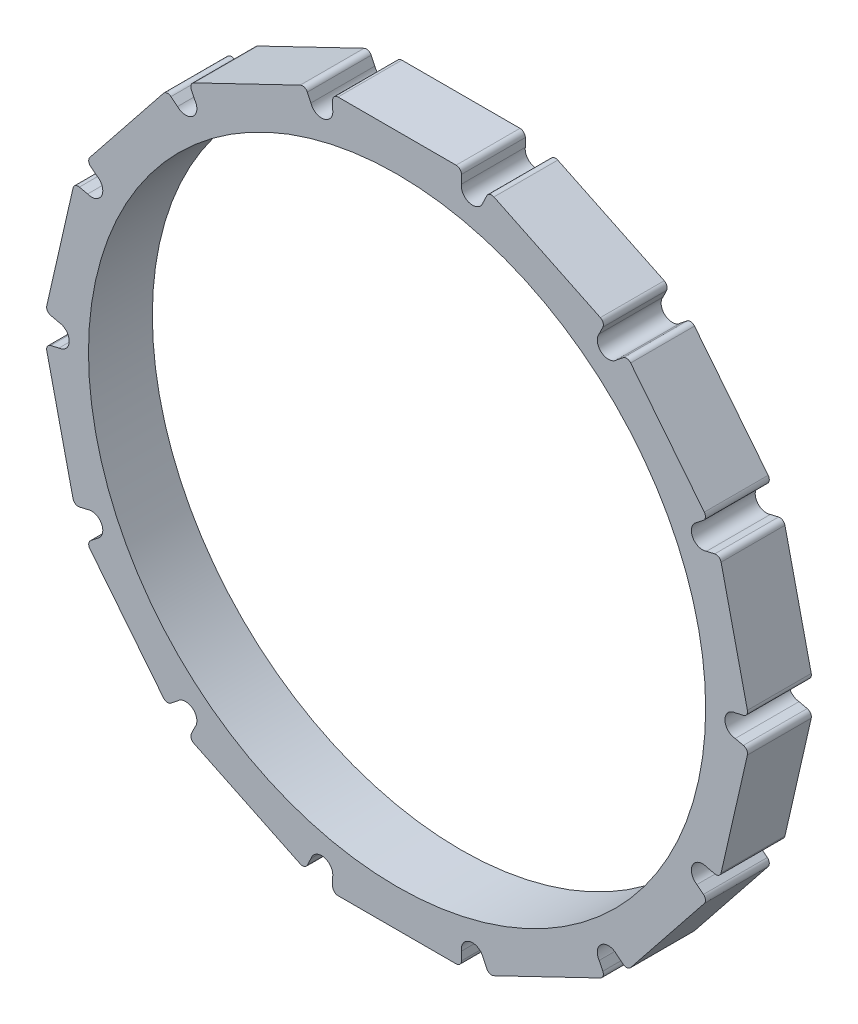
from build123d import *
from build123d.topology import SkipClean

# Parameters (mm, degrees)
SKETCH_1_R               = 34.5
EXTRUDE_1_DEPTH          = 4
SKETCH_2_R               = 31.5
EXTRUDE_2_DEPTH          = 3
SKETCH_3_W               = 12.1
SKETCH_3_H               = 2
EXTRUDE_3_DEPTH          = 3
PATTERN_CIRCULAR_1_COUNT = 14
SKETCH_5_R               = 1.05
CUT_EXTRUDE_1_DEPTH      = 3
PATTERN_CIRCULAR_2_COUNT = 14
SKETCH_6_R               = 4.5
CUT_EXTRUDE_2_DEPTH      = 50.289958409
SKETCH_7_R               = 29
SKETCH_7_R_2             = 10.5
CUT_EXTRUDE_3_DEPTH      = 50.289958409
CUT_EXTRUDE_3_DEPTH_BACK = 50.289958409
EXTRUDE_4_DEPTH          = 7
PATTERN_CIRCULAR_3_COUNT = 6
MIRROR_1_COPY_1_DEPTH    = 7
MIRROR_1_COPY_2_DEPTH    = 7
MIRROR_1_COPY_3_DEPTH    = 7
MIRROR_1_COPY_4_DEPTH    = 7
MIRROR_1_COPY_5_DEPTH    = 7
FILLET_1_R               = 0.5
FILLET_2_R               = 0.5
SKETCH_9_R               = 34.5
CUT_EXTRUDE_4_DEPTH      = 4
SKETCH_10_R              = 29
CUT_EXTRUDE_5_DEPTH      = 47.366061942
SKETCH_11_R              = 29
EXTRUDE_5_DEPTH          = 3


with BuildPart() as part:
    # ｽｹｯﾁ1 → ﾎﾞｽ - 押し出し1 (new body)
    with BuildSketch(Plane.XY):
        Circle(SKETCH_1_R)
    extrude(amount=EXTRUDE_1_DEPTH)

    # ｽｹｯﾁ2 → ﾎﾞｽ - 押し出し2 (add)
    with BuildSketch(Plane.XY.offset(4)):
        Circle(SKETCH_2_R)
    extrude(amount=EXTRUDE_2_DEPTH)

    # ｽｹｯﾁ3 → ﾎﾞｽ - 押し出し3 (add)
    with BuildSketch(Plane.XY.offset(4)):
        with Locations((0, 31.5)):
            Rectangle(SKETCH_3_W, SKETCH_3_H)
    extrude_3 = extrude(amount=EXTRUDE_3_DEPTH)

    # 円形ﾊﾟﾀｰﾝ1: ﾎﾞｽ - 押し出し3 ×14 about axis
    pattern_circular_1_axis = Axis((0, 0, 0), (0, 0, 1))
    for i in range(1, PATTERN_CIRCULAR_1_COUNT):
        add(extrude_3.rotate(pattern_circular_1_axis, i * 360 / PATTERN_CIRCULAR_1_COUNT))

    # ｽｹｯﾁ5 → ｶｯﾄ - 押し出し1 (cut)
    with BuildSketch(Plane.XY.offset(7)):
        with Locations((-7.089547386, 31.061336605)):
            Circle(SKETCH_5_R)
    cut_extrude_1 = extrude(amount=-CUT_EXTRUDE_1_DEPTH, mode=Mode.SUBTRACT)

    # 円形ﾊﾟﾀｰﾝ2: ｶｯﾄ - 押し出し1 ×14 about axis
    pattern_circular_2_axis = Axis((0, 0, 0), (0, 0, 1))
    for i in range(1, PATTERN_CIRCULAR_2_COUNT):
        add(cut_extrude_1.rotate(pattern_circular_2_axis, i * 360 / PATTERN_CIRCULAR_2_COUNT), mode=Mode.SUBTRACT)

    # ｽｹｯﾁ6 → ｶｯﾄ - 押し出し2 (cut, through all)
    with BuildSketch(Plane.XY.offset(7)):
        Circle(SKETCH_6_R)
    extrude(amount=-CUT_EXTRUDE_2_DEPTH, mode=Mode.SUBTRACT)

    # ｽｹｯﾁ7 → ｶｯﾄ - 押し出し3 (cut, two sides)
    with BuildSketch(Plane.XY.offset(7)) as cut_extrude_3_sk:
        Circle(SKETCH_7_R)
        Circle(SKETCH_7_R_2, mode=Mode.SUBTRACT)
    extrude(amount=CUT_EXTRUDE_3_DEPTH, mode=Mode.SUBTRACT)
    extrude(cut_extrude_3_sk.sketch, amount=-CUT_EXTRUDE_3_DEPTH_BACK, mode=Mode.SUBTRACT)


with BuildPart() as cut_extrude_3_piece_1:
    # of the separate pieces the step leaves, piece 1, a body of its own (cut_extrude_3_pieces)
    add(part.part.solids().sort_by_distance((34.5, 0, 0))[0])



with BuildPart() as cut_extrude_3_piece_2:
    # of the separate pieces the step leaves, piece 2, a body of its own (cut_extrude_3_pieces)
    add(part.part.solids().sort_by_distance((10.5, 0, 0))[0])


with BuildPart() as cut_extrude_3_piece_1_1:
    add(cut_extrude_3_piece_1.part)

    add(cut_extrude_3_piece_2.part)  # ﾎﾞｽ - 押し出し4 merges ｶｯﾄ - 押し出し3 piece 2
    # ｽｹｯﾁ8 → ﾎﾞｽ - 押し出し4 (add)
    with BuildSketch(Plane.XY.offset(7)):
        with BuildLine():
            Line((-10.232853034, 2.353448276), (-4.173869521, 28.698062883))
            ThreePointArc((-4.173869521, 28.698062883), (-2.092388157, 28.924417225), (0, 29))
            Line((0, 29), (-4.486334578, 9.493303011))
            ThreePointArc((-4.486334578, 9.493303011), (-8.179731193, 6.583463952), (-10.232853034, 2.353448276))
        make_face()
    extrude_4 = extrude(amount=-EXTRUDE_4_DEPTH)

    # 円形ﾊﾟﾀｰﾝ3: ﾎﾞｽ - 押し出し4 ×6 about axis
    pattern_circular_3_axis = Axis((0, 0, 0), (0, 0, 1))
    for i in range(1, PATTERN_CIRCULAR_3_COUNT):
        add(extrude_4.rotate(pattern_circular_3_axis, i * 360 / PATTERN_CIRCULAR_3_COUNT))

    # ﾐﾗｰ1: ﾎﾞｽ - 押し出し4 across plane
    add(extrude_4.mirror(Plane(origin=(0, 0, 0), x_dir=(0, 0, 1), z_dir=(1, 0, 0))))

    # ﾐﾗｰ1 copy 1 sketch → ﾐﾗｰ1 copy 1 (add)
    with BuildSketch(Plane(origin=(0, 0, 7), x_dir=(-0.5000000000000001, 0.8660254037844386, 0), z_dir=(0, 0, 1))):
        with BuildLine():
            Line((-10.232853034, -2.353448276), (-4.173869521, -28.698062883))
            ThreePointArc((-4.173869521, -28.698062883), (-2.092388157, -28.924417225), (0, -29))
            Line((0, -29), (-4.486334578, -9.493303011))
            ThreePointArc((-4.486334578, -9.493303011), (-8.179731193, -6.583463952), (-10.232853034, -2.353448276))
        make_face()
    extrude(amount=-MIRROR_1_COPY_1_DEPTH)

    # ﾐﾗｰ1 copy 2 sketch → ﾐﾗｰ1 copy 2 (add)
    with BuildSketch(Plane(origin=(0, 0, 7), x_dir=(0.4999999999999998, 0.8660254037844387, 0), z_dir=(0, 0, 1))):
        with BuildLine():
            Line((-10.232853034, -2.353448276), (-4.173869521, -28.698062883))
            ThreePointArc((-4.173869521, -28.698062883), (-2.092388157, -28.924417225), (0, -29))
            Line((0, -29), (-4.486334578, -9.493303011))
            ThreePointArc((-4.486334578, -9.493303011), (-8.179731193, -6.583463952), (-10.232853034, -2.353448276))
        make_face()
    extrude(amount=-MIRROR_1_COPY_2_DEPTH)

    # ﾐﾗｰ1 copy 3 sketch → ﾐﾗｰ1 copy 3 (add)
    with BuildSketch(Plane.XY.offset(7)):
        with BuildLine():
            Line((-10.232853034, -2.353448276), (-4.173869521, -28.698062883))
            ThreePointArc((-4.173869521, -28.698062883), (-2.092388157, -28.924417225), (0, -29))
            Line((0, -29), (-4.486334578, -9.493303011))
            ThreePointArc((-4.486334578, -9.493303011), (-8.179731193, -6.583463952), (-10.232853034, -2.353448276))
        make_face()
    extrude(amount=-MIRROR_1_COPY_3_DEPTH)

    # ﾐﾗｰ1 copy 4 sketch → ﾐﾗｰ1 copy 4 (add)
    with BuildSketch(Plane(origin=(0, 0, 7), x_dir=(0.5000000000000004, -0.8660254037844384, 0), z_dir=(0, 0, 1))):
        with BuildLine():
            Line((-10.232853034, -2.353448276), (-4.173869521, -28.698062883))
            ThreePointArc((-4.173869521, -28.698062883), (-2.092388157, -28.924417225), (0, -29))
            Line((0, -29), (-4.486334578, -9.493303011))
            ThreePointArc((-4.486334578, -9.493303011), (-8.179731193, -6.583463952), (-10.232853034, -2.353448276))
        make_face()
    extrude(amount=-MIRROR_1_COPY_4_DEPTH)

    # ﾐﾗｰ1 copy 5 sketch → ﾐﾗｰ1 copy 5 (add)
    with BuildSketch(Plane(origin=(0, 0, 7), x_dir=(-0.5000000000000001, -0.8660254037844386, 0), z_dir=(0, 0, 1))):
        with BuildLine():
            Line((-10.232853034, -2.353448276), (-4.173869521, -28.698062883))
            ThreePointArc((-4.173869521, -28.698062883), (-2.092388157, -28.924417225), (0, -29))
            Line((0, -29), (-4.486334578, -9.493303011))
            ThreePointArc((-4.486334578, -9.493303011), (-8.179731193, -6.583463952), (-10.232853034, -2.353448276))
        make_face()
    extrude(amount=-MIRROR_1_COPY_5_DEPTH)

    # ﾌｨﾚｯﾄ1
    fillet_1_edges = [cut_extrude_3_piece_1_1.edges().sort_by_distance(p)[0] for p in [
        (-30.338905495, -13.130244222, 5.5),
        (-33.031408796, -1.333616485, 5.5),
    ]]
    fillet(fillet_1_edges, radius=FILLET_1_R)

    # ﾌｨﾚｯﾄ2
    fillet_2_edges = [cut_extrude_3_piece_1_1.edges().sort_by_distance(p)[0] for p in [
        (-21.637409879, -24.993499029, 5.5),
        (-29.181636481, -15.533338091, 5.5),
        (-8.650359871, -31.906484828, 5.5),
        (-19.552083172, -26.656491585, 5.5),
        (6.05, -32.5, 5.5),
        (-6.05, -32.5, 5.5),
        (19.552083172, -26.656491585, 5.5),
        (8.650359871, -31.906484828, 5.5),
        (29.181636481, -15.533338091, 5.5),
        (21.637409879, -24.993499029, 5.5),
        (33.031408796, -1.333616485, 5.5),
        (30.338905495, -13.130244222, 5.5),
        (30.338905495, 13.130244222, 5.5),
        (33.031408796, 1.333616485, 5.5),
        (21.637409879, 24.993499029, 5.5),
        (29.181636481, 15.533338091, 5.5),
        (8.650359871, 31.906484828, 5.5),
        (19.552083172, 26.656491585, 5.5),
        (-6.05, 32.5, 5.5),
        (6.05, 32.5, 5.5),
        (-19.552083172, 26.656491585, 5.5),
        (-8.650359871, 31.906484828, 5.5),
        (-29.181636481, 15.533338091, 5.5),
        (-21.637409879, 24.993499029, 5.5),
        (-33.031408796, 1.333616485, 5.5),
        (-30.338905495, 13.130244222, 5.5),
    ]]
    fillet(fillet_2_edges, radius=FILLET_2_R)

    # ｽｹｯﾁ9 → ｶｯﾄ - 押し出し4 (cut)
    with BuildSketch(Plane(origin=(0, 0, 0), x_dir=(-1, 0, 0), z_dir=(0, 0, -1))):
        Circle(SKETCH_9_R)
    extrude(amount=-CUT_EXTRUDE_4_DEPTH, mode=Mode.SUBTRACT)

    # ｽｹｯﾁ10 → ｶｯﾄ - 押し出し5 (cut, through all)
    with BuildSketch(Plane.XY.offset(7)):
        Circle(SKETCH_10_R)
    extrude(amount=-CUT_EXTRUDE_5_DEPTH, mode=Mode.SUBTRACT)

    # ｽｹｯﾁ11 → ﾎﾞｽ - 押し出し5 (add)
    with SkipClean():  # the faces are left unmerged after this step: merging them gives an invalid solid
        with BuildSketch(Plane.XY.offset(7)):
            with BuildLine():
                Line((-19.101598738, -26.873433455), (-9.100844304, -31.689542959))
                ThreePointArc((-9.100844304, -31.689542959), (-8.718762904, -31.71100019), (-8.433418001, -31.456000395))
                Line((-8.433418001, -31.456000395), (-8.090269939, -30.743446101))
                ThreePointArc((-8.090269939, -30.743446101), (-6.855900405, -30.037662297), (-6.05, -31.2091244))
                Line((-6.05, -31.2091244), (-6.05, -32))
                ThreePointArc((-6.05, -32), (-5.903553391, -32.353553391), (-5.55, -32.5))
                Line((-5.55, -32.5), (5.55, -32.5))
                ThreePointArc((5.55, -32.5), (5.903553391, -32.353553391), (6.05, -32))
                Line((6.05, -32), (6.05, -31.2091244))
                ThreePointArc((6.05, -31.2091244), (6.855900405, -30.037662297), (8.090269939, -30.743446101))
                Line((8.090269939, -30.743446101), (8.433418001, -31.456000395))
                ThreePointArc((8.433418001, -31.456000395), (8.718762904, -31.71100019), (9.100844304, -31.689542959))
                Line((9.100844304, -31.689542959), (19.101598738, -26.873433455))
                ThreePointArc((19.101598738, -26.873433455), (19.356598534, -26.588088552), (19.335141303, -26.206007151))
                Line((19.335141303, -26.206007151), (18.99199324, -25.493452857))
                ThreePointArc((18.99199324, -25.493452857), (19.209806058, -24.088334891), (20.628162695, -24.188651257))
                Line((20.628162695, -24.188651257), (21.246494138, -24.681754128))
                ThreePointArc((21.246494138, -24.681754128), (21.614221277, -24.787694492), (21.94915478, -24.602583288))
                Line((21.94915478, -24.602583288), (28.869891581, -15.924253833))
                ThreePointArc((28.869891581, -15.924253833), (28.975831944, -15.556526694), (28.79072074, -15.221593191))
                Line((28.79072074, -15.221593191), (28.172389298, -14.72849032))
                ThreePointArc((28.172389298, -14.72849032), (27.758974029, -13.368017336), (29.080394842, -12.842997378))
                Line((29.080394842, -12.842997378), (29.851441539, -13.018983755))
                ThreePointArc((29.851441539, -13.018983755), (30.228718045, -12.954881899), (30.450165962, -12.642780266))
                Line((30.450165962, -12.642780266), (32.920148329, -1.821080441))
                ThreePointArc((32.920148329, -1.821080441), (32.856046473, -1.443803936), (32.54394484, -1.222356018))
                Line((32.54394484, -1.222356018), (31.772898143, -1.046369641))
                ThreePointArc((31.772898143, -1.046369641), (30.810136751, 0), (31.772898143, 1.046369641))
                Line((31.772898143, 1.046369641), (32.54394484, 1.222356018))
                ThreePointArc((32.54394484, 1.222356018), (32.856046473, 1.443803936), (32.920148329, 1.821080441))
                Line((32.920148329, 1.821080441), (30.450165962, 12.642780266))
                ThreePointArc((30.450165962, 12.642780266), (30.228718045, 12.954881899), (29.851441539, 13.018983755))
                Line((29.851441539, 13.018983755), (29.080394842, 12.842997378))
                ThreePointArc((29.080394842, 12.842997378), (27.758974029, 13.368017336), (28.172389298, 14.72849032))
                Line((28.172389298, 14.72849032), (28.79072074, 15.221593191))
                ThreePointArc((28.79072074, 15.221593191), (28.975831944, 15.556526694), (28.869891581, 15.924253833))
                Line((28.869891581, 15.924253833), (21.94915478, 24.602583288))
                ThreePointArc((21.94915478, 24.602583288), (21.614221277, 24.787694492), (21.246494138, 24.681754128))
                Line((21.246494138, 24.681754128), (20.628162695, 24.188651257))
                ThreePointArc((20.628162695, 24.188651257), (19.209806058, 24.088334891), (18.99199324, 25.493452857))
                Line((18.99199324, 25.493452857), (19.335141303, 26.206007151))
                ThreePointArc((19.335141303, 26.206007151), (19.356598534, 26.588088552), (19.101598738, 26.873433455))
                Line((19.101598738, 26.873433455), (9.100844304, 31.689542959))
                ThreePointArc((9.100844304, 31.689542959), (8.718762904, 31.71100019), (8.433418001, 31.456000395))
                Line((8.433418001, 31.456000395), (8.090269939, 30.743446101))
                ThreePointArc((8.090269939, 30.743446101), (6.855900405, 30.037662297), (6.05, 31.2091244))
                Line((6.05, 31.2091244), (6.05, 32))
                ThreePointArc((6.05, 32), (5.903553391, 32.353553391), (5.55, 32.5))
                Line((5.55, 32.5), (-5.55, 32.5))
                ThreePointArc((-5.55, 32.5), (-5.903553391, 32.353553391), (-6.05, 32))
                Line((-6.05, 32), (-6.05, 31.2091244))
                ThreePointArc((-6.05, 31.2091244), (-6.855900405, 30.037662297), (-8.090269939, 30.743446101))
                Line((-8.090269939, 30.743446101), (-8.433418001, 31.456000395))
                ThreePointArc((-8.433418001, 31.456000395), (-8.718762904, 31.71100019), (-9.100844304, 31.689542959))
                Line((-9.100844304, 31.689542959), (-19.101598738, 26.873433455))
                ThreePointArc((-19.101598738, 26.873433455), (-19.356598534, 26.588088552), (-19.335141303, 26.206007151))
                Line((-19.335141303, 26.206007151), (-18.99199324, 25.493452857))
                ThreePointArc((-18.99199324, 25.493452857), (-19.209806058, 24.088334891), (-20.628162695, 24.188651257))
                Line((-20.628162695, 24.188651257), (-21.246494138, 24.681754128))
                ThreePointArc((-21.246494138, 24.681754128), (-21.614221277, 24.787694492), (-21.94915478, 24.602583288))
                Line((-21.94915478, 24.602583288), (-28.869891581, 15.924253833))
                ThreePointArc((-28.869891581, 15.924253833), (-28.975831944, 15.556526694), (-28.79072074, 15.221593191))
                Line((-28.79072074, 15.221593191), (-28.172389298, 14.72849032))
                ThreePointArc((-28.172389298, 14.72849032), (-27.758974029, 13.368017336), (-29.080394842, 12.842997378))
                Line((-29.080394842, 12.842997378), (-29.851441539, 13.018983755))
                ThreePointArc((-29.851441539, 13.018983755), (-30.228718045, 12.954881899), (-30.450165962, 12.642780266))
                Line((-30.450165962, 12.642780266), (-32.920148329, 1.821080441))
                ThreePointArc((-32.920148329, 1.821080441), (-32.856046473, 1.443803936), (-32.54394484, 1.222356018))
                Line((-32.54394484, 1.222356018), (-31.772898143, 1.046369641))
                ThreePointArc((-31.772898143, 1.046369641), (-30.810136751, 0), (-31.772898143, -1.046369641))
                Line((-31.772898143, -1.046369641), (-32.54394484, -1.222356018))
                ThreePointArc((-32.54394484, -1.222356018), (-32.856046473, -1.443803936), (-32.920148329, -1.821080441))
                Line((-32.920148329, -1.821080441), (-30.450165962, -12.642780266))
                ThreePointArc((-30.450165962, -12.642780266), (-30.228718045, -12.954881899), (-29.851441539, -13.018983755))
                Line((-29.851441539, -13.018983755), (-29.080394842, -12.842997378))
                ThreePointArc((-29.080394842, -12.842997378), (-27.758974029, -13.368017336), (-28.172389298, -14.72849032))
                Line((-28.172389298, -14.72849032), (-28.79072074, -15.221593191))
                ThreePointArc((-28.79072074, -15.221593191), (-28.975831944, -15.556526694), (-28.869891581, -15.924253833))
                Line((-28.869891581, -15.924253833), (-21.94915478, -24.602583288))
                ThreePointArc((-21.94915478, -24.602583288), (-21.614221277, -24.787694492), (-21.246494138, -24.681754128))
                Line((-21.246494138, -24.681754128), (-20.628162695, -24.188651257))
                ThreePointArc((-20.628162695, -24.188651257), (-19.209806058, -24.088334891), (-18.99199324, -25.493452857))
                Line((-18.99199324, -25.493452857), (-19.335141303, -26.206007151))
                ThreePointArc((-19.335141303, -26.206007151), (-19.356598534, -26.588088552), (-19.101598738, -26.873433455))
            make_face()
            Circle(SKETCH_11_R, mode=Mode.SUBTRACT)
        extrude(amount=EXTRUDE_5_DEPTH)


solid = cut_extrude_3_piece_1_1.part
